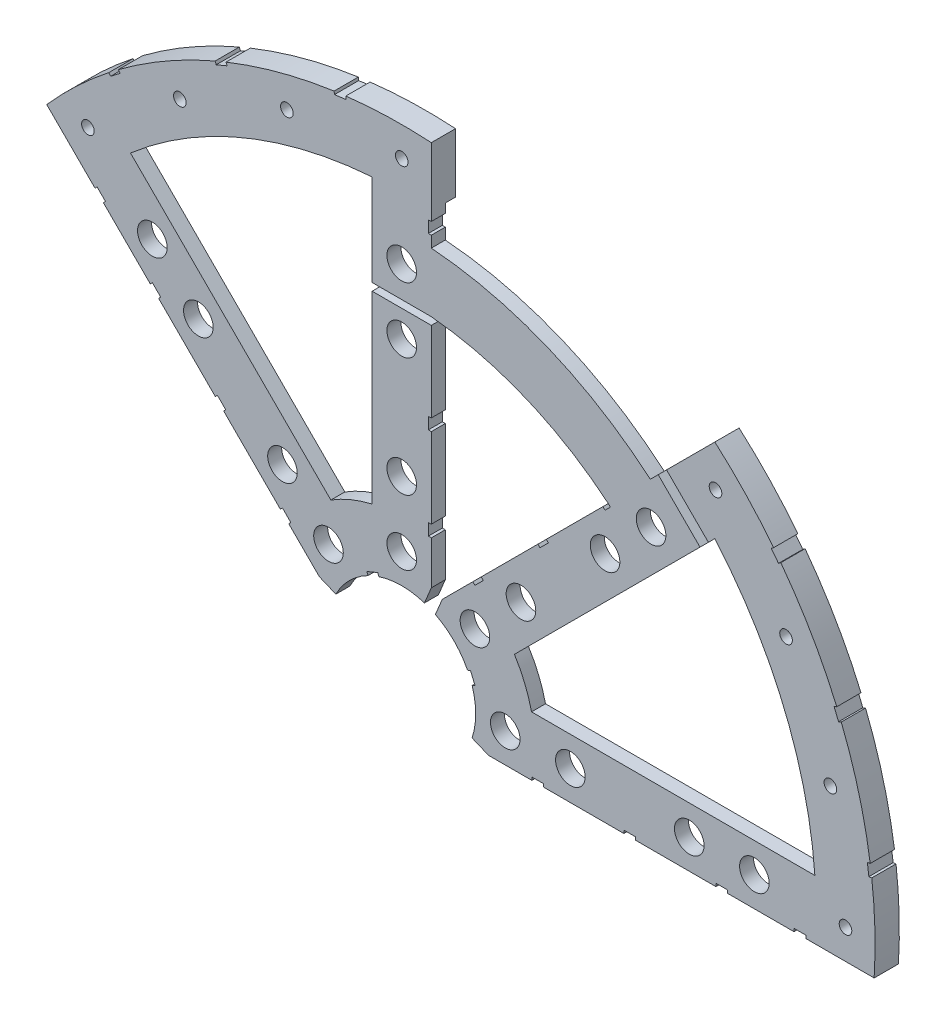
from build123d import *

# Parameters (mm, degrees)
BOSS_EXTRUDE1_DEPTH   = 3.000000096
BOSS_EXTRUDE2_DEPTH   = 2.206999904
SKETCH2_R             = 3.175
CUT_EXTRUDE1_DEPTH    = 6.207
SKETCH3_W             = 2.54
SKETCH3_H             = 0.635
SKETCH3_W_2           = 0.635
SKETCH3_H_2           = 2.54
SKETCH3_W_3           = 12.723081303
SKETCH3_H_3           = 1.613636956
CUT_EXTRUDE2_DEPTH    = 6.207
F_6_32_TAPPED_HOLE1_D = 2.7051


with BuildPart() as part:
    # Sketch1 → Boss-Extrude1 (new body)
    with BuildSketch(Plane.XY):
        with BuildLine():
            Line((8.696654013, 17.676910134), (44.336045576, 53.316301697))
            ThreePointArc((44.336045576, 53.316301697), (26.536034567, 64.063654543), (6.35, 69.050636956))
            Line((6.35, 69.050636956), (6.35, 18.648926052))
            Line((6.35, 18.648926052), (4.88230096, 15.105587123))
            ThreePointArc((4.88230096, 15.105587123), (-6.075099489, 14.666587579), (-14.133571205, 7.228954972))
            Line((-14.133571205, 7.228954972), (-17.676910134, 8.696654013))
            Line((-17.676910134, 8.696654013), (-76.191723231, 67.21146711))
            ThreePointArc((-76.191723231, 67.21146711), (-38.880636728, 93.866160503), (6.35, 101.401368334))
            Line((6.35, 101.401368334), (6.35, 81.795887818))
            ThreePointArc((6.35, 81.795887818), (31.396114158, 75.796924606), (53.348298889, 62.32855501))
            Line((53.348298889, 62.32855501), (67.21146711, 76.191723231))
            ThreePointArc((67.21146711, 76.191723231), (93.866160503, 38.880636728), (101.401368334, -6.35))
            Line((101.401368334, -6.35), (18.648926052, -6.35))
            Line((18.648926052, -6.35), (15.105587123, -4.88230096))
            ThreePointArc((15.105587123, -4.88230096), (14.666587579, 6.075099489), (7.228954972, 14.133571205))
            Line((7.228954972, 14.133571205), (8.696654013, 17.676910134))
        make_face()
        with BuildLine():
            Line((88.672924278, 6.35), (27.86051193, 6.35))
            ThreePointArc((27.86051193, 6.35), (26.399857642, 10.93517908), (24.190484974, 15.210228852))
            Line((24.190484974, 15.210228852), (67.191354125, 58.211098004))
            ThreePointArc((67.191354125, 58.211098004), (82.13289044, 34.020557137), (88.672924278, 6.35))
        make_face(mode=Mode.SUBTRACT)
        with BuildLine():
            Line((-58.211098004, 67.191354125), (-15.210228852, 24.190484974))
            ThreePointArc((-15.210228852, 24.190484974), (-10.93517908, 26.399857642), (-6.35, 27.86051193))
            Line((-6.35, 27.86051193), (-6.35, 88.672924278))
            ThreePointArc((-6.35, 88.672924278), (-34.020557137, 82.13289044), (-58.211098004, 67.191354125))
        make_face(mode=Mode.SUBTRACT)
    extrude(amount=BOSS_EXTRUDE1_DEPTH)

    # Sketch4 → Boss-Extrude2 (add)
    with BuildSketch(Plane(origin=(0, 0, 0), x_dir=(-1, 0, 0), z_dir=(0, 0, -1))):
        with BuildLine():
            Line((67.191354125, 58.211098004), (76.191723231, 67.21146711))
            ThreePointArc((76.191723231, 67.21146711), (38.880636728, 93.866160503), (-6.35, 101.401368334))
            Line((-6.35, 101.401368334), (-6.35, 88.672924278))
            ThreePointArc((-6.35, 88.672924278), (34.020557137, 82.13289044), (67.191354125, 58.211098004))
        make_face()
        with BuildLine():
            Line((-58.211098004, 67.191354125), (-67.21146711, 76.191723231))
            ThreePointArc((-67.21146711, 76.191723231), (-93.866160503, 38.880636728), (-101.401368334, -6.35))
            Line((-101.401368334, -6.35), (-88.672924278, -6.35))
            ThreePointArc((-88.672924278, -6.35), (-82.13289044, 34.020557137), (-58.211098004, 67.191354125))
        make_face()
    extrude(amount=BOSS_EXTRUDE2_DEPTH)

    # Sketch2 → Cut-Extrude1 (cut, through all)
    with BuildSketch(Plane.XY.offset(3.000000096)):
        with Locations((22.225, 0)):
            Circle(SKETCH2_R)
        with Locations((36.195, 0)):
            Circle(SKETCH2_R)
        with Locations((61.722, 0)):
            Circle(SKETCH2_R)
        with Locations((75.692, 0)):
            Circle(SKETCH2_R)
        with Locations((53.522326482, 53.522326482)):
            Circle(SKETCH2_R)
        with Locations((43.644044748, 43.644044748)):
            Circle(SKETCH2_R)
        with Locations((25.593729945, 25.593729945)):
            Circle(SKETCH2_R)
        with Locations((15.715448212, 15.715448212)):
            Circle(SKETCH2_R)
        with Locations((0, 75.692)):
            Circle(SKETCH2_R)
        with Locations((0, 61.722)):
            Circle(SKETCH2_R)
        with Locations((0, 36.195)):
            Circle(SKETCH2_R)
        with Locations((0, 22.225)):
            Circle(SKETCH2_R)
        with Locations((-53.522326482, 53.522326482)):
            Circle(SKETCH2_R)
        with Locations((-43.644044748, 43.644044748)):
            Circle(SKETCH2_R)
        with Locations((-25.593729945, 25.593729945)):
            Circle(SKETCH2_R)
        with Locations((-15.715448212, 15.715448212)):
            Circle(SKETCH2_R)
    extrude(amount=-CUT_EXTRUDE1_DEPTH, mode=Mode.SUBTRACT)

    # Sketch3 → Cut-Extrude2 (cut, through all)
    with BuildSketch(Plane.XY.offset(3.000000096)):
        Polygon((15.266435406, 24.246691527), (17.06248663, 26.042742751), (17.511499436, 25.593729945), (15.715448212, 23.797678721), align=None)
        Polygon((55.048970022, 64.029226143), (56.845021246, 65.825277367), (65.85268206, 56.817616554), (64.056630836, 55.02156533), align=None)
        Polygon((29.230733674, 38.210989795), (31.026784898, 40.007041019), (31.475797704, 39.558028213), (29.67974648, 37.761976989), align=None)
        with Locations((29.21, -6.0325)):
            Rectangle(SKETCH3_W, SKETCH3_H)
        with Locations((68.707, -6.0325)):
            Rectangle(SKETCH3_W, SKETCH3_H)
        Polygon((-65.825277367, 56.845021246), (-64.029226143, 55.048970022), (-63.580213337, 55.497982828), (-65.376264561, 57.294034052), align=None)
        Polygon((43.195031942, 52.175288063), (44.336045576, 53.316301697), (44.785058382, 52.867288891), (43.644044748, 51.726275257), align=None)
        with Locations((48.9585, -6.0325)):
            Rectangle(SKETCH3_W, SKETCH3_H)
        with Locations((85.471, -6.0325)):
            Rectangle(SKETCH3_W, SKETCH3_H)
        Polygon((99.935462164, 14.437711971), (100.266998693, 11.919442024), (101.526133667, 12.085210288), (101.194597138, 14.603480236), align=None)
        Polygon((93.765504959, 37.464305742), (94.938831965, 37.950313702), (93.966816047, 40.296967714), (92.793489041, 39.810959755), align=None)
        Polygon((79.327792988, 62.471156422), (80.874047017, 60.456038938), (81.88160576, 61.229165953), (80.33535173, 63.244283437), align=None)
        Polygon((13.593916116, 7.005422516), (14.565932035, 4.658768503), (15.739259041, 5.144776462), (14.767243123, 7.491430475), align=None)
        Polygon((-24.246691527, 15.266435406), (-26.042742751, 17.06248663), (-25.593729945, 17.511499436), (-23.797678721, 15.715448212), align=None)
        Polygon((-40.007041019, 31.026784898), (-38.210989795, 29.230733674), (-37.761976989, 29.67974648), (-39.558028213, 31.475797704), align=None)
        Polygon((-63.244283437, 80.33535173), (-61.229165953, 81.88160576), (-60.456038938, 80.874047017), (-62.471156422, 79.327792988), align=None)
        Polygon((-37.950313702, 94.938831965), (-40.296967714, 93.966816047), (-39.810959755, 92.793489041), (-37.464305742, 93.765504959), align=None)
        Polygon((-14.437711971, 99.935462164), (-14.603480236, 101.194597138), (-12.085210288, 101.526133667), (-11.919442024, 100.266998693), align=None)
        with Locations((6.0325, 85.471)):
            Rectangle(SKETCH3_W_2, SKETCH3_H_2)
        with Locations((6.0325, 48.9585)):
            Rectangle(SKETCH3_W_2, SKETCH3_H_2)
        with Locations((6.0325, 29.21)):
            Rectangle(SKETCH3_W_2, SKETCH3_H_2)
        Polygon((-7.491430475, 14.767243123), (-5.144776462, 15.739259041), (-4.658768503, 14.565932035), (-7.005422516, 13.593916116), align=None)
        with Locations((-0.011540651, 68.243818478)):
            Rectangle(SKETCH3_W_3, SKETCH3_H_3)
        Polygon((-53.971339288, 44.991083167), (-52.175288063, 43.195031942), (-51.726275257, 43.644044748), (-53.522326482, 45.440095973), align=None)
    extrude(amount=-CUT_EXTRUDE2_DEPTH, mode=Mode.SUBTRACT)

    # #6-32 Tapped Hole1 (through all)
    with Locations(Plane.XY.offset(3.000000096)):
        with Locations((95.25, 0), (92.004434954, 24.652514046), (82.48891971, 47.625), (67.351920908, 67.351920908), (47.625, 82.48891971), (24.652514046, 92.004434954), (0, 95.25), (-24.652514046, 92.004434954), (-47.625, 82.48891971), (-67.351920908, 67.351920908)):
            Hole(F_6_32_TAPPED_HOLE1_D / 2)


solid = part.part
